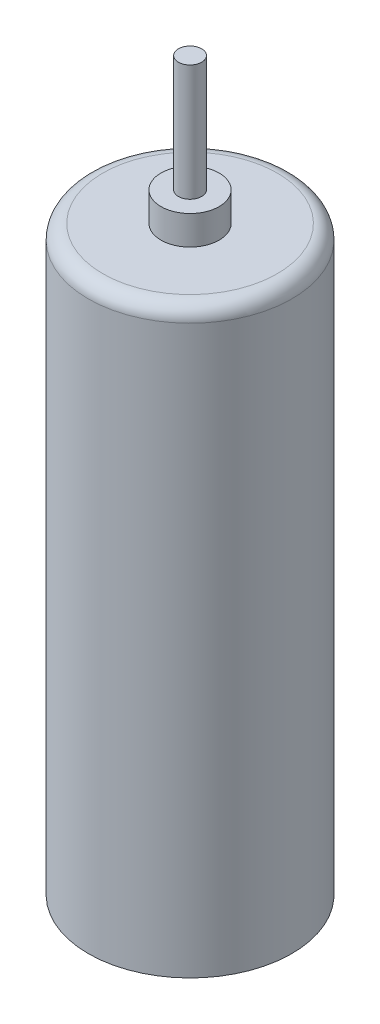
from build123d import *

# Parameters (mm, degrees)
SKETCH1_R           = 3.5
BOSS_EXTRUDE1_DEPTH = 20
SKETCH2_R           = 1
BOSS_EXTRUDE2_DEPTH = 1
SKETCH3_R           = 0.4
BOSS_EXTRUDE3_DEPTH = 5
FILLET1_R           = 0.5


with BuildPart() as part:
    # Sketch1 → Boss-Extrude1 (new body)
    with BuildSketch(Plane(origin=(0, 0, 0), x_dir=(1, 0, 0), z_dir=(0, 1, 0))):
        Circle(SKETCH1_R)
    extrude(amount=BOSS_EXTRUDE1_DEPTH)

    # Sketch2 → Boss-Extrude2 (add)
    with BuildSketch(Plane(origin=(0, 20, 0), x_dir=(1, 0, 0), z_dir=(0, 1, 0))):
        Circle(SKETCH2_R)
    extrude(amount=BOSS_EXTRUDE2_DEPTH)

    # Sketch3 → Boss-Extrude3 (add)
    with BuildSketch(Plane(origin=(0, 20, 0), x_dir=(1, 0, 0), z_dir=(0, 1, 0))):
        Circle(SKETCH3_R)
    extrude(amount=BOSS_EXTRUDE3_DEPTH)

    # Fillet1
    fillet1_edges = [part.edges().sort_by_distance(p)[0] for p in [
        (-3.5, 20, 0),
    ]]
    fillet(fillet1_edges, radius=FILLET1_R)


solid = part.part
